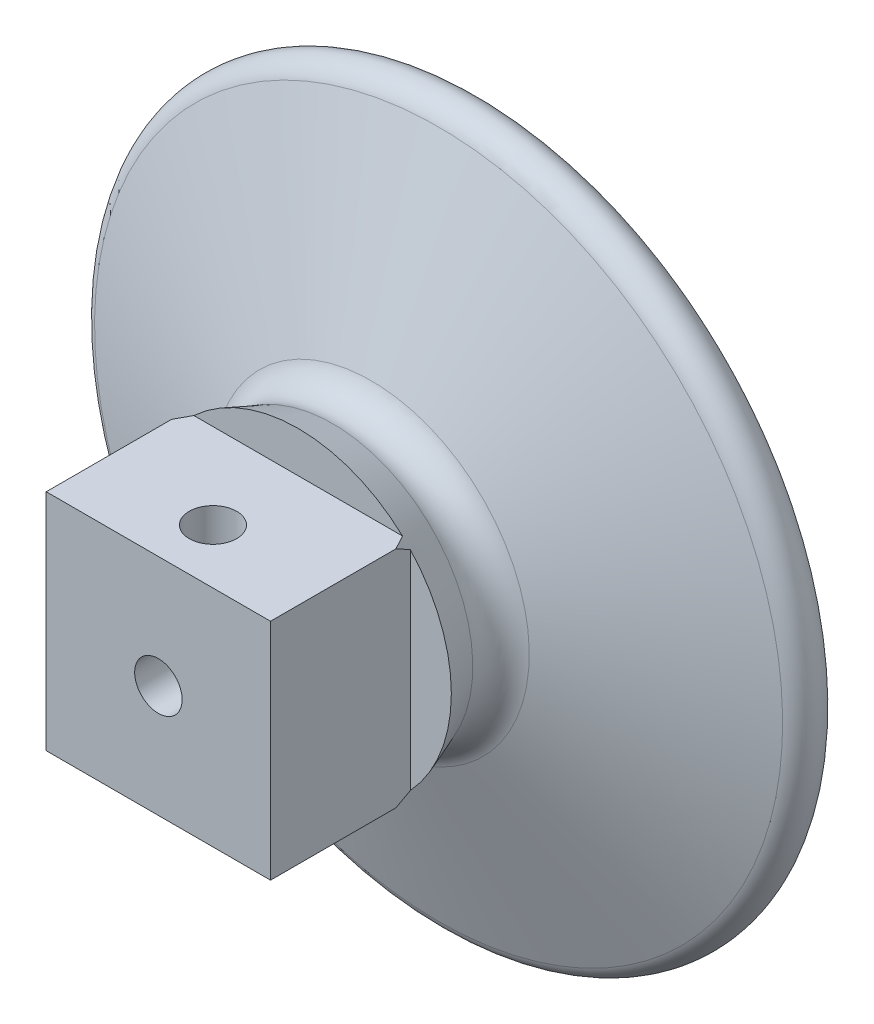
from build123d import *

# Parameters (mm, degrees)
SKETCH3_R                      = 1.5875
CUT_EXTRUDE1_DEPTH             = 1.5000001
CUT_EXTRUDE1_DEPTH_BACK        = 34.456537644
CUT_EXTRUDE2_REACH             = 70.5
SKETCH5_R                      = 1.5875
CUT_EXTRUDE2_DIRECTION_2_DEPTH = 1
CUT_EXTRUDE3_START             = -5.7
SKETCH7_W                      = 73.641561492
SKETCH7_H                      = 95.167537828
SKETCH7_W_2                    = 15
SKETCH7_H_2                    = 15
CUT_EXTRUDE3_DEPTH             = 30
SKETCH8_W                      = 22.620718333
SKETCH8_H                      = 11.010276543
CUT_EXTRUDE4_DEPTH             = 19


with BuildPart() as part:
    # Sketch2 → Revolve1 (revolve)
    with BuildSketch(Plane(origin=(0, 0, 0), x_dir=(0, 0, -1), z_dir=(1, 0, 0))):
        with BuildLine():
            Line((8, 9.378044922), (-13.252418104, 17.371955078))
            ThreePointArc((-13.252418104, 17.371955078), (-15.64910376, 16.565466847), (-15.34, 14.055689912))
            ThreePointArc((-15.34, 14.055689912), (-10.902736423, 7.641374531), (-9.34, 0))
            Line((-9.34, 0), (17.5, 0))
            Line((17.5, 0), (17.5, 21.381966011))
            ThreePointArc((17.5, 21.381966011), (17.339814217, 23.742864466), (15.089610413, 23.010687001))
            Line((15.089610413, 23.010687001), (10.584638888, 10.569083998))
            ThreePointArc((10.584638888, 10.569083998), (9.541151557, 9.433581206), (8, 9.378044922))
        make_face()
    revolve(axis=Axis((0, 0, 9.34), (0, 0, -1)))

    # Sketch6 → Cut-Revolve1 (revolve, cut)
    with BuildSketch(Plane(origin=(0, 0, 0), x_dir=(1, 0, 0), z_dir=(0, 1, 0))):
        Polygon((-15.003814977, -6.956537544), (-14.995054438, -6.959832743), (-17.361955078, -13.252418104), (-17.371955078, -13.252418104), align=None)
    revolve(axis=Axis((0, 0, 0), (0, 0, 1)), mode=Mode.SUBTRACT)

    # Sketch3 → Cut-Extrude1 (cut, two sides)
    with BuildSketch(Plane(origin=(0, 0, -17.5), x_dir=(-1, 0, 0), z_dir=(0, 0, -1))) as cut_extrude1_sk:
        Circle(SKETCH3_R)
    extrude(amount=CUT_EXTRUDE1_DEPTH, mode=Mode.SUBTRACT)
    extrude(cut_extrude1_sk.sketch, amount=-CUT_EXTRUDE1_DEPTH_BACK, mode=Mode.SUBTRACT)

    # Sketch4 → Revolve2 (revolve)
    with BuildSketch(Plane.XY):
        Polygon((0, 1.5875), (5.5, 1.5875), (5.5, 28.5), (4.5, 28.5), (4, 32.5), (4.5, 32.5), (4, 36.5), (4.5, 36.5), (4, 40.5), (4.5, 40.5), (4, 44.5), (0, 44.5), (0, 28.5), align=None)
    revolve(axis=Axis((0, 0, 0), (0, 1, 0)))

    # Sketch5 → Cut-Extrude2 (cut, up to next)
    with BuildSketch(Plane(origin=(0, 44.5, 0), x_dir=(1, 0, 0), z_dir=(0, 1, 0)), mode=Mode.PRIVATE) as cut_extrude2_sk1:
        Circle(SKETCH5_R)
    cut_extrude2_tool1 = extrude(cut_extrude2_sk1.sketch, amount=-CUT_EXTRUDE2_REACH, mode=Mode.PRIVATE) & part.part
    add(cut_extrude2_tool1.solids().sort_by_distance((0, 44.5, 0))[0], mode=Mode.SUBTRACT)

    # Sketch5 → Cut-Extrude2 direction 2 (cut)
    with BuildSketch(Plane(origin=(0, 44.5, 0), x_dir=(1, 0, 0), z_dir=(0, 1, 0))):
        Circle(SKETCH5_R)
    extrude(amount=CUT_EXTRUDE2_DIRECTION_2_DEPTH, mode=Mode.SUBTRACT)

    # Sketch7 → Cut-Extrude3 (cut)
    with BuildSketch(Plane.XY.offset(CUT_EXTRUDE3_START)):
        Rectangle(SKETCH7_W, SKETCH7_H)
        Rectangle(SKETCH7_W_2, SKETCH7_H_2, mode=Mode.SUBTRACT)
    extrude(amount=CUT_EXTRUDE3_DEPTH, mode=Mode.SUBTRACT)

    # Sketch8 → Cut-Extrude4 (cut)
    with BuildSketch(Plane(origin=(0, 7.5, 0), x_dir=(1, 0, 0), z_dir=(0, 1, 0))):
        with Locations((2.733336799, -9.155138272)):
            Rectangle(SKETCH8_W, SKETCH8_H)
    extrude(amount=-CUT_EXTRUDE4_DEPTH, mode=Mode.SUBTRACT)


solid = part.part
